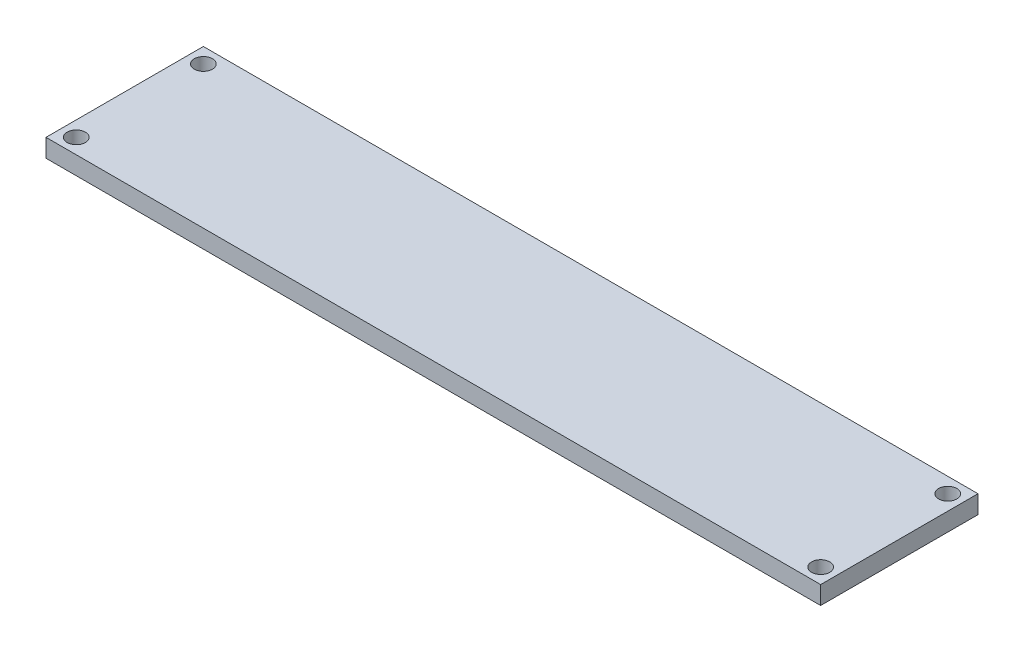
from build123d import *

# Parameters (mm, degrees)
SKETCH1_W           = 128
SKETCH1_H           = 26
SKETCH1_R           = 1.5
BOSS_EXTRUDE1_DEPTH = 3


with BuildPart() as part:
    # Sketch1 → Boss-Extrude1 (new body)
    with BuildSketch(Plane(origin=(0, 0, 0), x_dir=(1, 0, 0), z_dir=(0, 1, 0))):
        Rectangle(SKETCH1_W, SKETCH1_H)
        with Locations((-61.5, 10.5)):
            Circle(SKETCH1_R, mode=Mode.SUBTRACT)
        with Locations((61.5, 10.5)):
            Circle(SKETCH1_R, mode=Mode.SUBTRACT)
        with Locations((61.5, -10.5)):
            Circle(SKETCH1_R, mode=Mode.SUBTRACT)
        with Locations((-61.5, -10.5)):
            Circle(SKETCH1_R, mode=Mode.SUBTRACT)
    extrude(amount=-BOSS_EXTRUDE1_DEPTH)


solid = part.part
